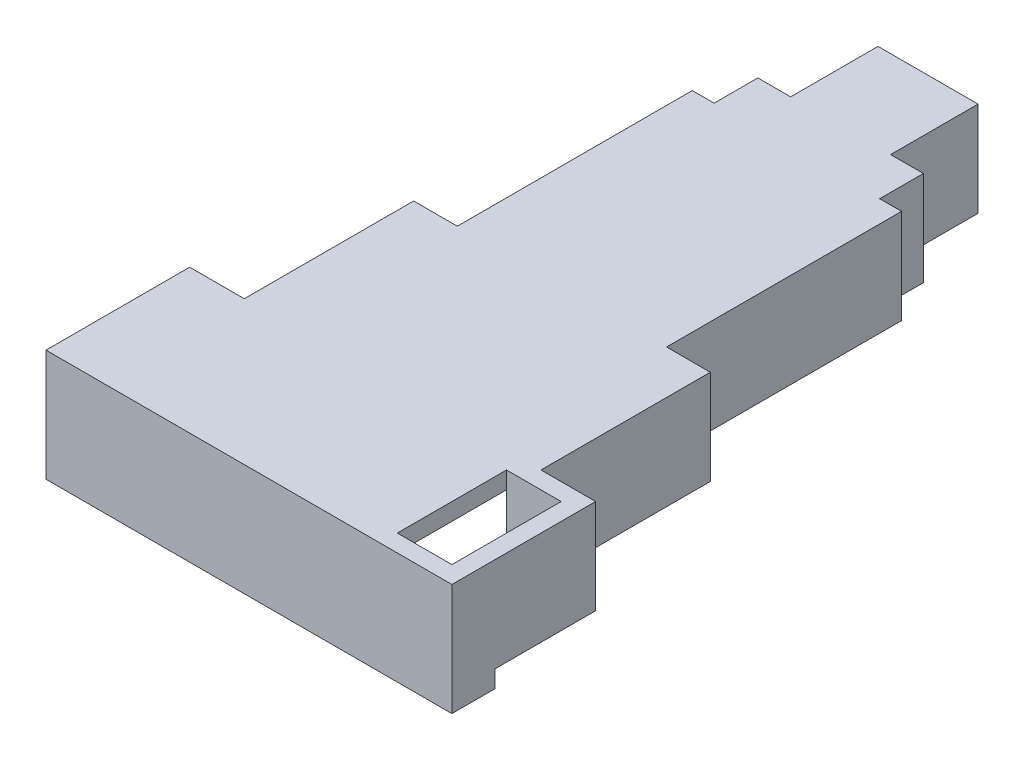
from build123d import *

# Parameters (mm, degrees)
BOSS_EXTRUDE2_DEPTH     = 9
BOSS_EXTRUDE3_DEPTH     = 2
SKETCH3_W               = 47.18
SKETCH3_H               = 5
BOSS_EXTRUDE4_DEPTH     = 2
SKETCH5_W               = 6.35
SKETCH5_H               = 12.7
CUT_EXTRUDE1_DEPTH      = 12
CUT_EXTRUDE1_DEPTH_BACK = 10
BOSS_EXTRUDE5_START     = 8
BOSS_EXTRUDE5_DEPTH     = 10
BOSS_EXTRUDE6_START     = 8
BOSS_EXTRUDE6_DEPTH     = 10
CUT_EXTRUDE2_DEPTH      = 8


with BuildPart() as part:
    # Sketch1 → Boss-Extrude2 (new body)
    with BuildSketch(Plane(origin=(0, 0, 0), x_dir=(1, 0, 0), z_dir=(0, 1, 0))):
        Polygon((9.43, 34.38), (9.43, 61.69), (11.97, 61.69), (11.97, 66.77), (15.78, 66.77), (15.78, 76.93), (27.4, 76.93), (27.4, 66.77), (31.21, 66.77), (31.21, 61.69), (33.75, 61.69), (33.75, 34.38), (38.83, 34.38), (38.83, 14.7), (45.18, 14.7), (45.18, -2), (-2, -2), (-2, 14.7), (4.35, 14.7), (4.35, 34.38), align=None)
        Polygon((0, 0), (0, 12.7), (6.35, 12.7), (6.35, 32.38), (11.43, 32.38), (11.43, 59.69), (13.97, 59.69), (13.97, 64.77), (17.78, 64.77), (17.78, 74.93), (25.4, 74.93), (25.4, 64.77), (29.21, 64.77), (29.21, 59.69), (31.75, 59.69), (31.75, 32.38), (36.83, 32.38), (36.83, 12.7), (43.18, 12.7), (43.18, 0), align=None, mode=Mode.SUBTRACT)
    extrude(amount=BOSS_EXTRUDE2_DEPTH)

    # Sketch2 → Boss-Extrude3 (add)
    with BuildSketch(Plane(origin=(0, 9, 0), x_dir=(1, 0, 0), z_dir=(0, 1, 0))):
        Polygon((-2, -2), (-2, 14.7), (4.35, 14.7), (4.35, 34.38), (9.43, 34.38), (9.43, 61.69), (11.97, 61.69), (11.97, 66.77), (15.78, 66.77), (15.78, 76.93), (27.4, 76.93), (27.4, 66.77), (31.21, 66.77), (31.21, 61.69), (33.75, 61.69), (33.75, 34.38), (38.83, 34.38), (38.83, 14.7), (45.18, 14.7), (45.18, -2), align=None)
    extrude(amount=BOSS_EXTRUDE3_DEPTH)

    # Sketch3 → Boss-Extrude4 (add)
    with BuildSketch(Plane.XZ):
        with Locations((21.59, -0.5)):
            Rectangle(SKETCH3_W, SKETCH3_H)
    extrude(amount=BOSS_EXTRUDE4_DEPTH)

    # Sketch5 → Cut-Extrude1 (cut, two sides)
    with BuildSketch(Plane.XZ.offset(-9)) as cut_extrude1_sk:
        with Locations((40.005, -6.35)):
            Rectangle(SKETCH5_W, SKETCH5_H)
    extrude(amount=CUT_EXTRUDE1_DEPTH, mode=Mode.SUBTRACT)
    extrude(cut_extrude1_sk.sketch, amount=-CUT_EXTRUDE1_DEPTH_BACK, mode=Mode.SUBTRACT)

    # Sketch8 → Boss-Extrude5 (add)
    with BuildSketch(Plane.XY.offset(-59.69).offset(BOSS_EXTRUDE5_START)):
        Polygon((11.43, 0), (12.43, 1), (11.43, 2), (11.43, 1), align=None)
    extrude(amount=BOSS_EXTRUDE5_DEPTH)

    # Sketch9 → Boss-Extrude6 (add)
    with BuildSketch(Plane.XY.offset(-59.69).offset(BOSS_EXTRUDE6_START)):
        Polygon((31.75, 0), (31.75, 1), (31.75, 2), (30.75, 1), align=None)
    extrude(amount=BOSS_EXTRUDE6_DEPTH)

    # Sketch10 → Cut-Extrude2 (cut)
    with BuildSketch(Plane.XZ.offset(2)):
        Polygon((31.270231455, -3), (10.582199871, -3), (10.582199871, 0), (31.270231455, 0), (42.389768545, 0), (42.389768545, -6), (31.270231455, -6), align=None)
    extrude(amount=-CUT_EXTRUDE2_DEPTH, mode=Mode.SUBTRACT)


solid = part.part
